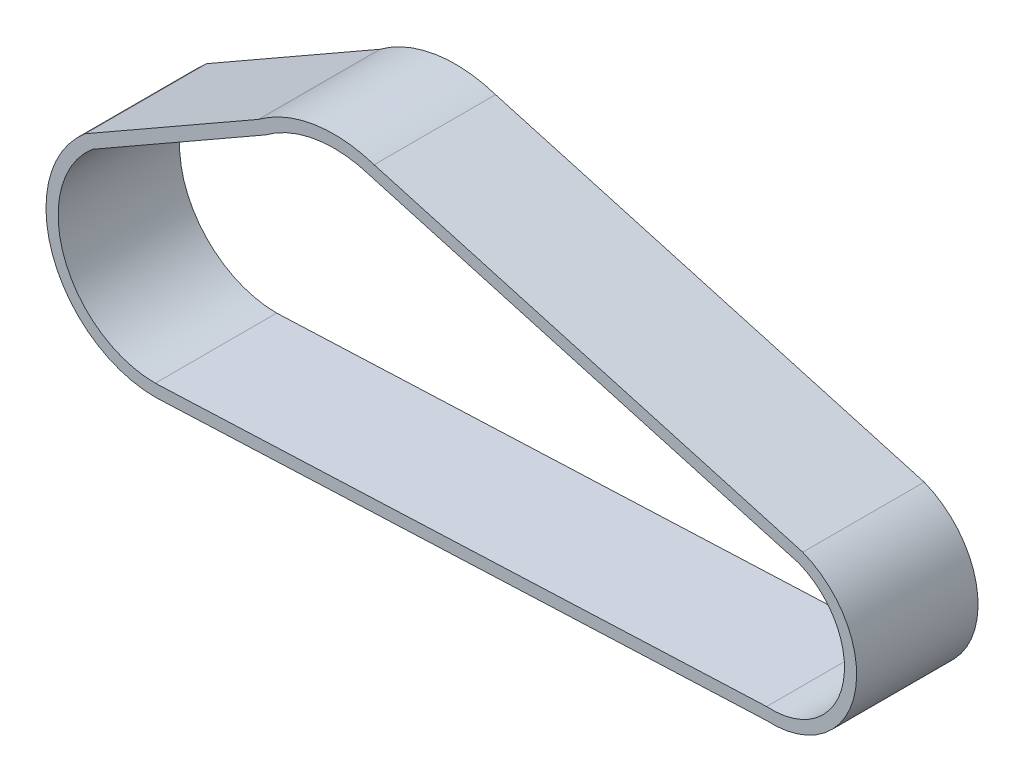
from build123d import *

# Parameters (mm, degrees)
ESTRUSIONE_SOTTILE1_DEPTH      = 25
ESTRUSIONE_SOTTILE1_DEPTH_BACK = 25
SCALE2_SCALE                   = 0.93


with BuildPart() as part:
    # Schizzo2 → Estrusione-Sottile1 (new, two sides)
    with BuildSketch(Plane(origin=(-3.626199773, -4.388168382, 0), x_dir=(1, 0, 0), z_dir=(0, 0, 1))) as estrusione_sottile1_sk:
        with BuildLine():
            Line((-226.626080874, -48.830329598), (24.988136504, -38.271646045))
            ThreePointArc((24.988136504, -38.271646045), (61.276185696, -10.897676453), (39.925535167, 29.230947338))
            Line((39.925535167, 29.230947338), (-136.579797, 79.141284263))
            ThreePointArc((-136.579797, 79.141284263), (-161.317329277, 81.14637928), (-184.196927163, 71.52921183))
            Line((-184.196927163, 71.52921183), (-255.562423669, 30.722741893))
            ThreePointArc((-255.562423669, 30.722741893), (-269.023375691, -19.212630891), (-226.626080874, -48.830329598))
        make_face()
        with BuildLine():
            Line((-226.734029631, -43.830459075), (25.044382174, -33.264885303))
            ThreePointArc((25.044382174, -33.264885303), (56.34084272, -10.054333528), (38.316167271, 24.489974706))
            Line((38.316167271, 24.489974706), (-138.050550004, 74.361115557))
            ThreePointArc((-138.050550004, 74.361115557), (-160.616278185, 76.194878875), (-181.452431457, 67.338836133))
            Line((-181.452431457, 67.338836133), (-252.686438473, 26.607551295))
            ThreePointArc((-252.686438473, 26.607551295), (-264.26748414, -17.659406707), (-226.734029631, -43.830459075))
        make_face(mode=Mode.SUBTRACT)
    extrude(amount=ESTRUSIONE_SOTTILE1_DEPTH)
    extrude(estrusione_sottile1_sk.sketch, amount=-ESTRUSIONE_SOTTILE1_DEPTH_BACK)


with BuildPart() as part_1:
    # Scale2: scaled about (-111.699071241, 1.574242956, 0)
    add(part.part.scale(SCALE2_SCALE).moved(Location((-7.818934987, 0.110197007, 0))))


solid = part_1.part
